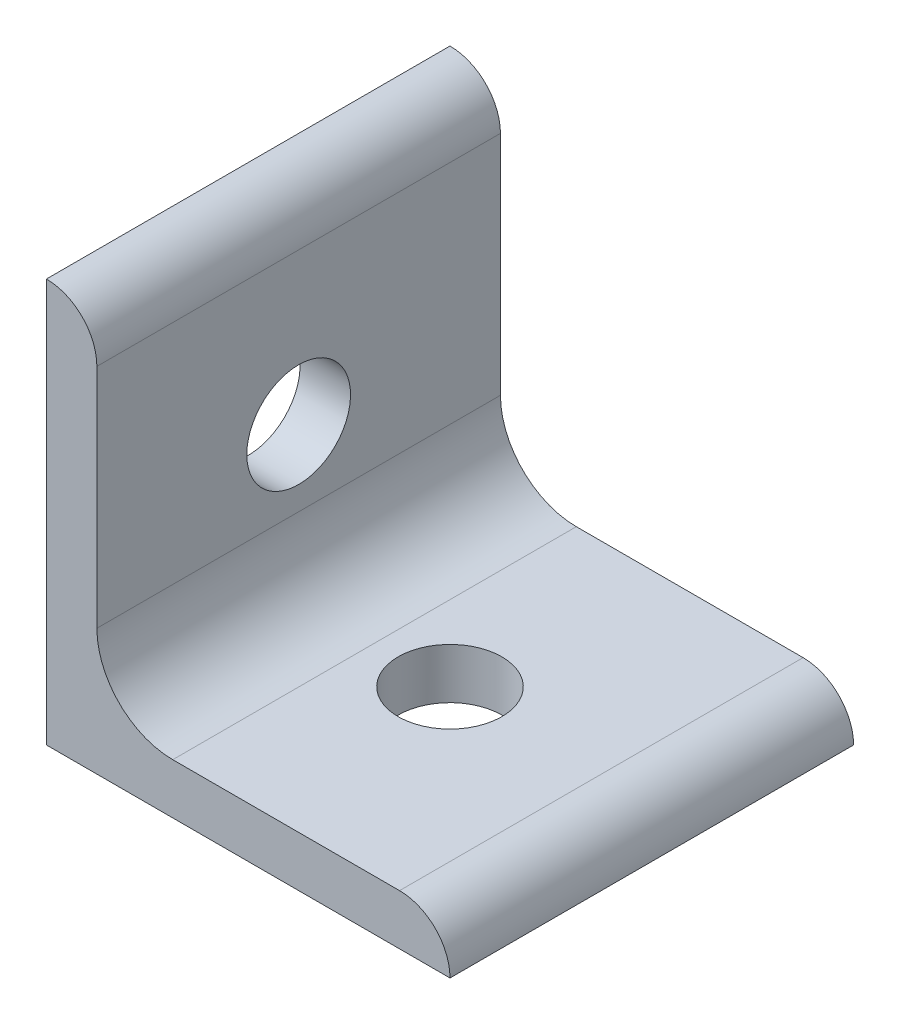
from build123d import *

# Parameters (mm, degrees)
BOSS_EXTRUDE1_DEPTH      = 25.4
M6_CLEARANCE_HOLE1_D     = 6.5278
M6_CLEARANCE_HOLE1_DEPTH = 25.4
M6_CLEARANCE_HOLE2_D     = 6.5278
M6_CLEARANCE_HOLE2_DEPTH = 25.4
FILLET1_R                = 4.7752


with BuildPart() as part:
    # Sketch1 → Boss-Extrude1 (new body)
    with BuildSketch(Plane.XY.offset(25.4)):
        with BuildLine():
            Line((23.473046964, -1.696403207), (23.473046964, -27.096403207))
            Line((23.473046964, -27.096403207), (48.873046964, -27.096403207))
            ThreePointArc((48.873046964, -27.096403207), (47.943110995, -24.851339177), (45.698046964, -23.921403207))
            Line((45.698046964, -23.921403207), (26.648046964, -23.921403207))
            Line((26.648046964, -23.921403207), (26.648046964, -4.871403207))
            ThreePointArc((26.648046964, -4.871403207), (25.718110995, -2.626339177), (23.473046964, -1.696403207))
        make_face()
    extrude(amount=-BOSS_EXTRUDE1_DEPTH)

    # M6 Clearance Hole1
    with Locations(Plane.XZ.offset(27.096403207)):
        with Locations((36.173046964, 12.7)):
            Hole(M6_CLEARANCE_HOLE1_D / 2, depth=M6_CLEARANCE_HOLE1_DEPTH)

    # M6 Clearance Hole2
    with Locations(Plane.ZY.offset(-23.473046964)):
        with Locations((12.7, -14.396403207)):
            Hole(M6_CLEARANCE_HOLE2_D / 2, depth=M6_CLEARANCE_HOLE2_DEPTH)

    # Fillet1
    fillet1_edges = [part.edges().sort_by_distance(p)[0] for p in [
        (26.648046964, -23.921403207, 12.7),
    ]]
    fillet(fillet1_edges, radius=FILLET1_R)


solid = part.part
